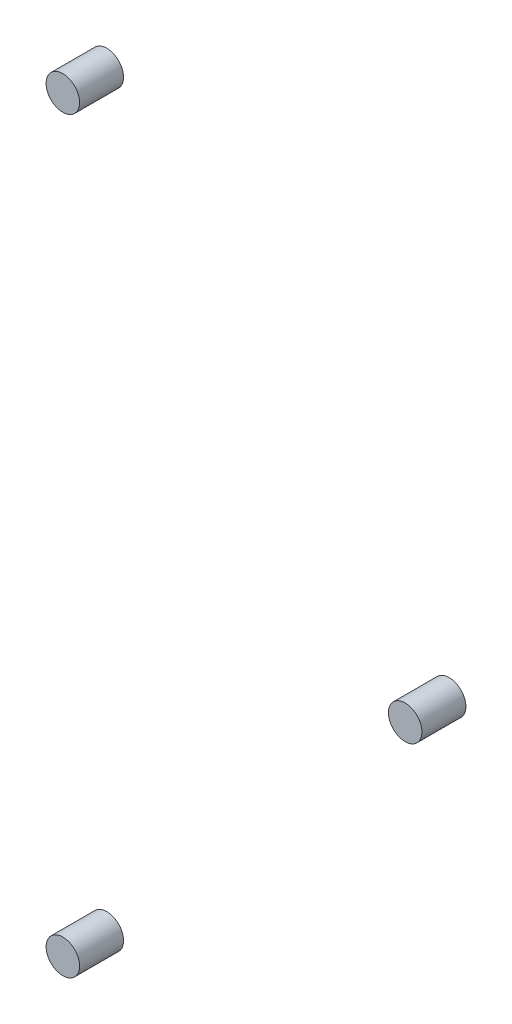
from build123d import *

# Parameters (mm, degrees)
SKETCH_1_R        = 1.525
EXTRUDE_1_DEPTH   = 4
EXTRUDE_1_2_DEPTH = 4
EXTRUDE_1_3_DEPTH = 4


with BuildPart() as part:
    # 草图1 → 凸台-拉伸1 (new body)
    with BuildSketch(Plane.XY):
        with Locations((37.849897884, 34.020782514)):
            Circle(SKETCH_1_R)
    extrude(amount=EXTRUDE_1_DEPTH)


with BuildPart() as body_2:
    # 草图1 → Extrude 1 2 (new body)
    with BuildSketch(Plane.XY):
        with Locations((69, 0)):
            Circle(SKETCH_1_R)
    extrude(amount=EXTRUDE_1_2_DEPTH)


with BuildPart() as body_3:
    # 草图1 → Extrude 1 3 (new body)
    with BuildSketch(Plane.XY):
        with Locations((37.849897884, -34.020782514)):
            Circle(SKETCH_1_R)
    extrude(amount=EXTRUDE_1_3_DEPTH)


solid = Compound([part.part, body_2.part, body_3.part])
